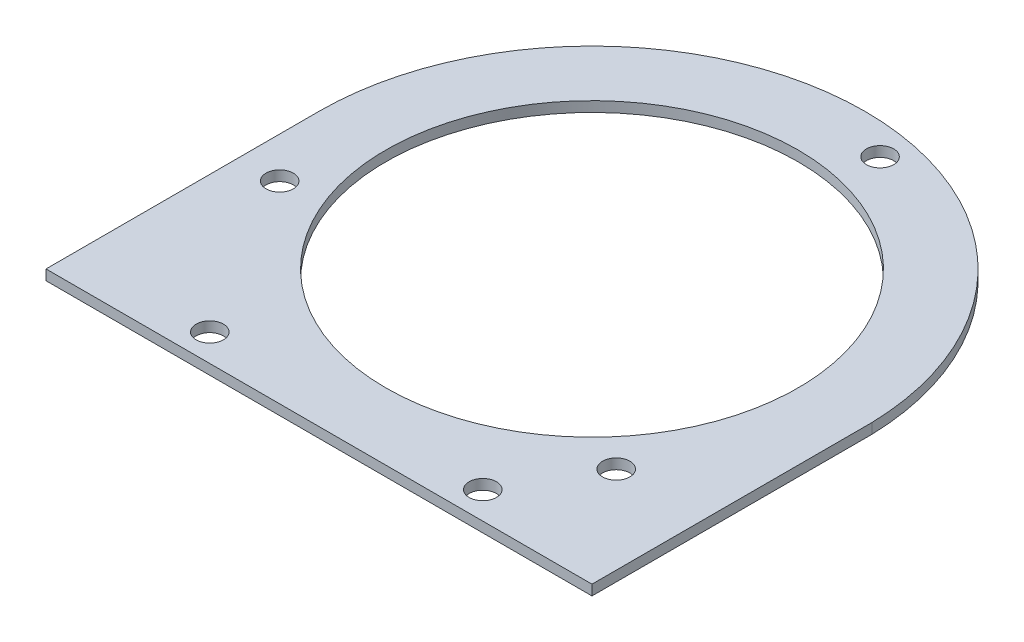
from build123d import *

# Parameters (mm, degrees)
SKETCH1_R           = 95.885
SKETCH1_R_2         = 6.35
BOSS_EXTRUDE1_DEPTH = 4.7625


with BuildPart() as part:
    # Sketch1 → Boss-Extrude1 (new body)
    with BuildSketch(Plane(origin=(0, 0, 0), x_dir=(1, 0, 0), z_dir=(0, 1, 0))):
        with BuildLine():
            Line((127, -127), (-127, -127))
            Line((-127, -127), (-127, 0))
            ThreePointArc((-127, 0), (-89.802561208, 89.802561213), (7e-09, 127))
            ThreePointArc((7e-09, 127), (88.687133546, 90.920457479), (127, 3.175))
            Line((127, 3.175), (127, -127))
        make_face()
        Circle(SKETCH1_R, mode=Mode.SUBTRACT)
        with Locations((-108.072773191, -37.212440054)):
            Circle(SKETCH1_R_2, mode=Mode.SUBTRACT)
        with Locations((21.809468172, 112.199987068)):
            Circle(SKETCH1_R_2, mode=Mode.SUBTRACT)
        with Locations((86.263305019, -74.987547014)):
            Circle(SKETCH1_R_2, mode=Mode.SUBTRACT)
        with Locations((-63.5, -114.3)):
            Circle(SKETCH1_R_2, mode=Mode.SUBTRACT)
        with Locations((63.5, -114.3)):
            Circle(SKETCH1_R_2, mode=Mode.SUBTRACT)
    extrude(amount=BOSS_EXTRUDE1_DEPTH)


solid = part.part
